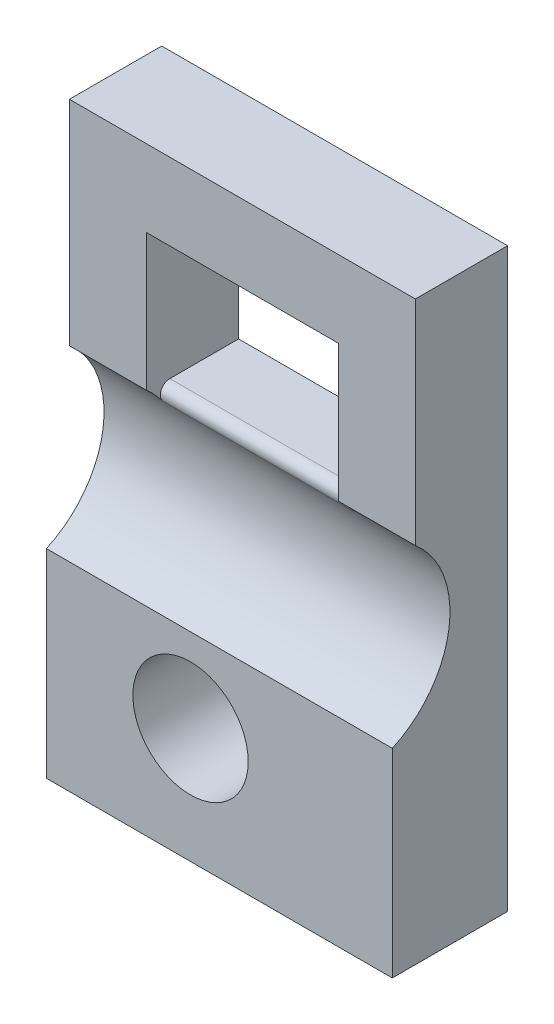
from build123d import *

# Parameters (mm, degrees)
SKETCH1_W           = 18
SKETCH1_H           = 30
SKETCH1_R           = 3
SKETCH1_W_2         = 10
SKETCH1_H_2         = 7.2
BOSS_EXTRUDE1_DEPTH = 6
CUT_EXTRUDE1_DEPTH  = 19
FILLET1_R           = 0.5


with BuildPart() as part:
    # Sketch1 → Boss-Extrude1 (new body)
    with BuildSketch(Plane.XY):
        with Locations((9, 15)):
            Rectangle(SKETCH1_W, SKETCH1_H)
        with Locations((7.5, 6)):
            Circle(SKETCH1_R, mode=Mode.SUBTRACT)
        with Locations((9, 22.4)):
            Rectangle(SKETCH1_W_2, SKETCH1_H_2, mode=Mode.SUBTRACT)
    extrude(amount=BOSS_EXTRUDE1_DEPTH)

    # Sketch2 → Cut-Extrude1 (cut, through all)
    with BuildSketch(Plane(origin=(18, 0, 0), x_dir=(0, 0, -1), z_dir=(1, 0, 0))):
        with BuildLine():
            Line((-4.8, 18.888444419), (-4.8, 30))
            Line((-4.8, 30), (-6, 30))
            Line((-6, 30), (-6, 10.352419985))
            ThreePointArc((-6, 10.352419985), (-3.049660577, 14.29001992), (-4.8, 18.888444419))
        make_face()
    extrude(amount=-CUT_EXTRUDE1_DEPTH, mode=Mode.SUBTRACT)

    # Fillet1
    fillet1_edges = [part.edges().sort_by_distance(p)[0] for p in [
        (9, 18.8, 4.69852973),
    ]]
    fillet(fillet1_edges, radius=FILLET1_R)


solid = part.part
